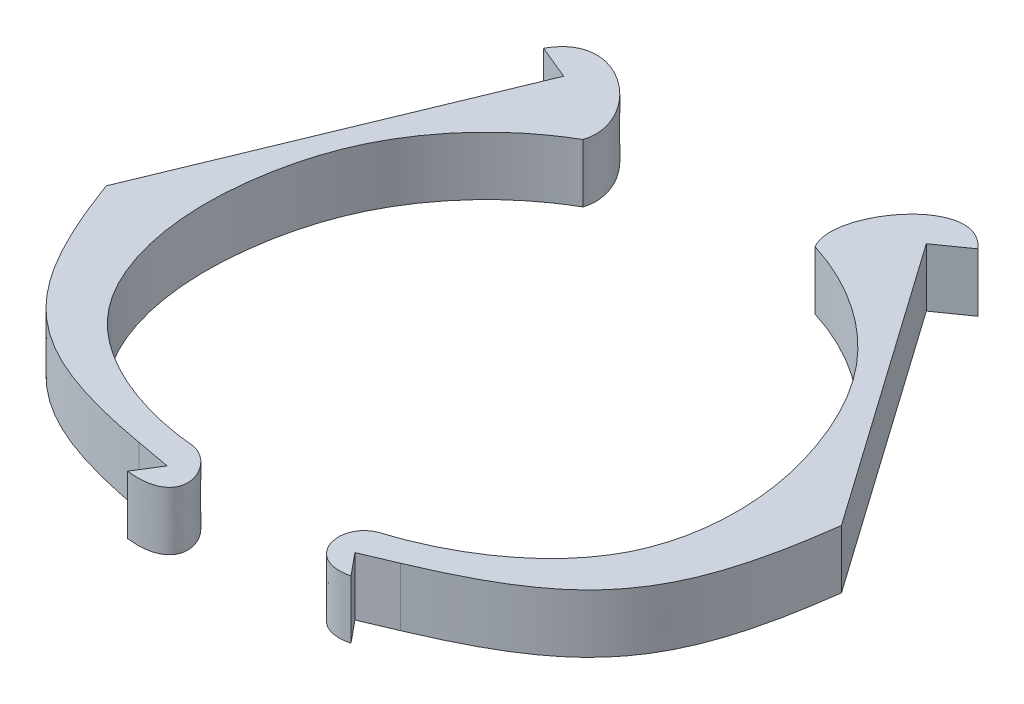
from build123d import *

# Parameters (mm, degrees)
BOSS_EXTRUDE1_DEPTH   = 10
BOSS_EXTRUDE1_2_DEPTH = 10


with BuildPart() as part:
    # Sketch1 → Boss-Extrude1 (new body)
    with BuildSketch(Plane(origin=(0, 0, 0), x_dir=(1, 0, 0), z_dir=(0, 1, 0))):
        with BuildLine():
            Line((-33.486602419, 46.749285127), (-56.403682484, -8.701661135))
            add(Edge.make_bspline(
                [(-56.403682484, -8.701661135), (-47.619362092, -32.517163226), (-39.471979778, -39.592078969), (-15.535090126, -43.932368814)],
                knots=[0, 0, 0, 0, 1, 1, 1, 1], degree=3))
            Line((-15.535090126, -43.932368814), (-9.647057112, -45))
            Line((-9.647057112, -45), (-12.261451972, -49.18120574))
            add(Edge.make_bspline(
                [(-10.254452676, -39.83663767), (-5.199461627, -41.013476487), (-1.694300478, -50.418800059), (-12.261451972, -49.18120574)],
                knots=[0, 0, 0, 0, 1, 1, 1, 1], degree=3))
            add(Edge.make_bspline(
                [(-22.451536716, 38.999083311), (-26.86197021, 36.469439855), (-33.627219214, 30.834724001), (-41.582367215, 19.043107829), (-45.581483474, 4.470319547), (-45.430056142, -12.166693994), (-36.949699035, -32.846128329), (-20.131629562, -39.004157196), (-10.254452676, -39.83663767)],
                knots=[0, 0, 0, 0, 0.143153018, 0.245274506, 0.396893762, 0.561689325, 0.708961154, 1, 1, 1, 1], degree=3))
            add(Edge.make_bspline(
                [(-22.451536716, 38.999083311), (-19.908993881, 46.665508044), (-34.13051951, 58.821468348), (-39.345472777, 49.170672138)],
                knots=[0, 0, 0, 0, 1, 1, 1, 1], degree=3))
            Line((-39.345472777, 49.170672138), (-33.486602419, 46.749285127))
        make_face()
    extrude(amount=BOSS_EXTRUDE1_DEPTH)


with BuildPart() as body_2:
    # Sketch1 → Boss-Extrude1 2 (new body)
    with BuildSketch(Plane(origin=(0, 0, 0), x_dir=(1, 0, 0), z_dir=(0, 1, 0))):
        with BuildLine():
            Line((19.292764236, -41.78342924), (24.802663686, -39.448953457))
            add(Edge.make_bspline(
                [(56.937828511, 3.895893832), (53.59733097, -21.267243905), (47.202309681, -29.95850239), (24.802663686, -39.448953457)],
                knots=[0, 0, 0, 0, 1, 1, 1, 1], degree=3))
            Line((56.937828511, 3.895893832), (22.404075684, 52.961359444))
            Line((22.404075684, 52.961359444), (27.58826498, 56.610148048))
            add(Edge.make_bspline(
                [(13.340127184, 42.977214972), (9.176234824, 49.898240378), (20.381453857, 64.88030394), (27.58826498, 56.610148048)],
                knots=[0, 0, 0, 0, 1, 1, 1, 1], degree=3))
            add(Edge.make_bspline(
                [(13.340127184, 42.977214972), (18.198382679, 41.47775735), (26.035797936, 37.466082022), (36.386010934, 27.709049555), (43.487435054, 14.370051668), (46.992877656, -1.89417355), (43.260303643, -23.931037037), (28.204878822, -33.63170525), (18.751558917, -36.612710071)],
                knots=[0, 0, 0, 0, 0.143153018, 0.245274506, 0.396893762, 0.561689325, 0.708961154, 1, 1, 1, 1], degree=3))
            add(Edge.make_bspline(
                [(18.751558917, -36.612710071), (13.113327903, -38.302450089), (15.345170537, -47.380531105), (22.404075684, -45.565384067)],
                knots=[0, 0, 0, 0, 1, 1, 1, 1], degree=3))
            Line((22.404075684, -45.565384067), (19.292764236, -41.78342924))
        make_face()
    extrude(amount=BOSS_EXTRUDE1_2_DEPTH)


solid = Compound([part.part, body_2.part])
